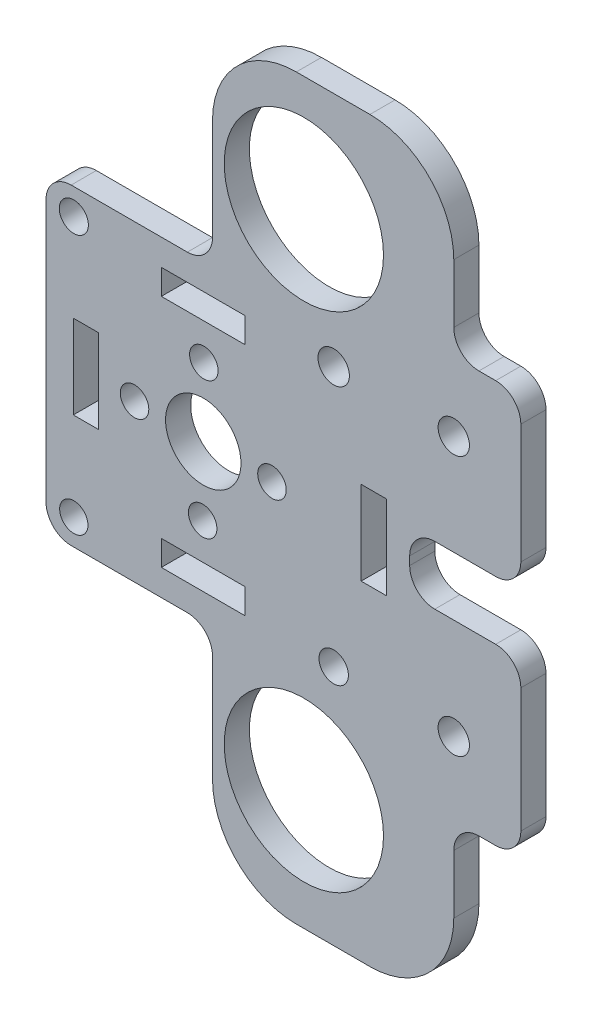
from build123d import *

# Parameters (mm, degrees)
SKETCH1_R           = 1.737885662
SKETCH1_R_2         = 1.873200063
SKETCH1_R_3         = 1.690089146
SKETCH1_R_4         = 1.754205974
SKETCH1_R_5         = 1.7
SKETCH1_R_6         = 4.5
SKETCH1_R_7         = 1.87
SKETCH1_R_8         = 9.5
SKETCH1_W           = 3
SKETCH1_H           = 10
SKETCH1_W_2         = 10
SKETCH1_H_2         = 3
BOSS_EXTRUDE1_DEPTH = 3
FILLET1_R           = 10
FILLET2_R           = 3


with BuildPart() as part:
    # Sketch1 → Boss-Extrude1 (new body)
    with BuildSketch(Plane.XY):
        Polygon((147.061964125, -92.970138098), (147.061964125, -71.856515964), (147.061964125, -67.856515964), (175.843347401, -67.856515964), (175.843347401, -87.856515964), (183.843347401, -87.856515964), (183.843347401, -108.090292187), (170.582125914, -108.090292187), (170.582125914, -115.091712302), (183.843347401, -115.091712302), (183.843347401, -135.887076434), (175.843347401, -135.887076434), (175.843347401, -155.887076434), (147.061964125, -155.887076434), (147.061964125, -151.887076434), (147.061964125, -130.215533927), (127.203791419, -130.215533927), (127.203791419, -111.591712302), (127.203791419, -92.970138098), align=None)
        with Locations((130.520049527, -96.082032258)):
            Circle(SKETCH1_R, mode=Mode.SUBTRACT)
        with Locations((161.520049527, -96.082032258)):
            Circle(SKETCH1_R_2, mode=Mode.SUBTRACT)
        with Locations((130.520049527, -127.114221831)):
            Circle(SKETCH1_R_3, mode=Mode.SUBTRACT)
        with Locations((161.520049527, -127.082032258)):
            Circle(SKETCH1_R_4, mode=Mode.SUBTRACT)
        with Locations((154.157584865, -111.662272701)):
            Circle(SKETCH1_R_5, mode=Mode.SUBTRACT)
        with Locations((145.89014032, -119.788596448)):
            Circle(SKETCH1_R_5, mode=Mode.SUBTRACT)
        with Locations((137.763816574, -111.521151903)):
            Circle(SKETCH1_R_5, mode=Mode.SUBTRACT)
        with Locations((146.031261118, -103.394828157)):
            Circle(SKETCH1_R_5, mode=Mode.SUBTRACT)
        with Locations((145.960700719, -111.591712302)):
            Circle(SKETCH1_R_6, mode=Mode.SUBTRACT)
        with Locations((175.843347401, -96.114221831)):
            Circle(SKETCH1_R_7, mode=Mode.SUBTRACT)
        with Locations((157.960700719, -81.591712302)):
            Circle(SKETCH1_R_8, mode=Mode.SUBTRACT)
        with Locations((157.960700719, -141.591712302)):
            Circle(SKETCH1_R_8, mode=Mode.SUBTRACT)
        with Locations((175.843347401, -127.114221831)):
            Circle(SKETCH1_R_7, mode=Mode.SUBTRACT)
        with Locations((131.960700719, -111.591712302)):
            Rectangle(SKETCH1_W, SKETCH1_H, mode=Mode.SUBTRACT)
        with Locations((145.960700719, -97.591712302)):
            Rectangle(SKETCH1_W_2, SKETCH1_H_2, mode=Mode.SUBTRACT)
        with Locations((145.960700719, -125.591712302)):
            Rectangle(SKETCH1_W_2, SKETCH1_H_2, mode=Mode.SUBTRACT)
        with Locations((166.293610901, -111.591712302)):
            Rectangle(SKETCH1_W, SKETCH1_H, mode=Mode.SUBTRACT)
    extrude(amount=BOSS_EXTRUDE1_DEPTH)

    # Fillet1
    fillet1_edges = [part.edges().sort_by_distance(p)[0] for p in [
        (147.061964125, -67.856515964, 1.5),
        (175.843347401, -67.856515964, 1.5),
        (175.843347401, -155.887076434, 1.5),
        (147.061964125, -155.887076434, 1.5),
    ]]
    fillet(fillet1_edges, radius=FILLET1_R)

    # Fillet2
    fillet2_edges = [part.edges().sort_by_distance(p)[0] for p in [
        (175.843347401, -87.856515964, 1.5),
        (183.843347401, -87.856515964, 1.5),
        (183.843347401, -108.090292187, 1.5),
        (170.582125914, -108.090292187, 1.5),
        (170.582125914, -115.091712302, 1.5),
        (183.843347401, -115.091712302, 1.5),
        (183.843347401, -135.887076434, 1.5),
        (175.843347401, -135.887076434, 1.5),
        (147.061964125, -130.215533927, 1.5),
        (127.203791419, -130.215533927, 1.5),
        (127.203791419, -92.970138098, 1.5),
        (147.061964125, -92.970138098, 1.5),
    ]]
    fillet(fillet2_edges, radius=FILLET2_R)


solid = part.part
